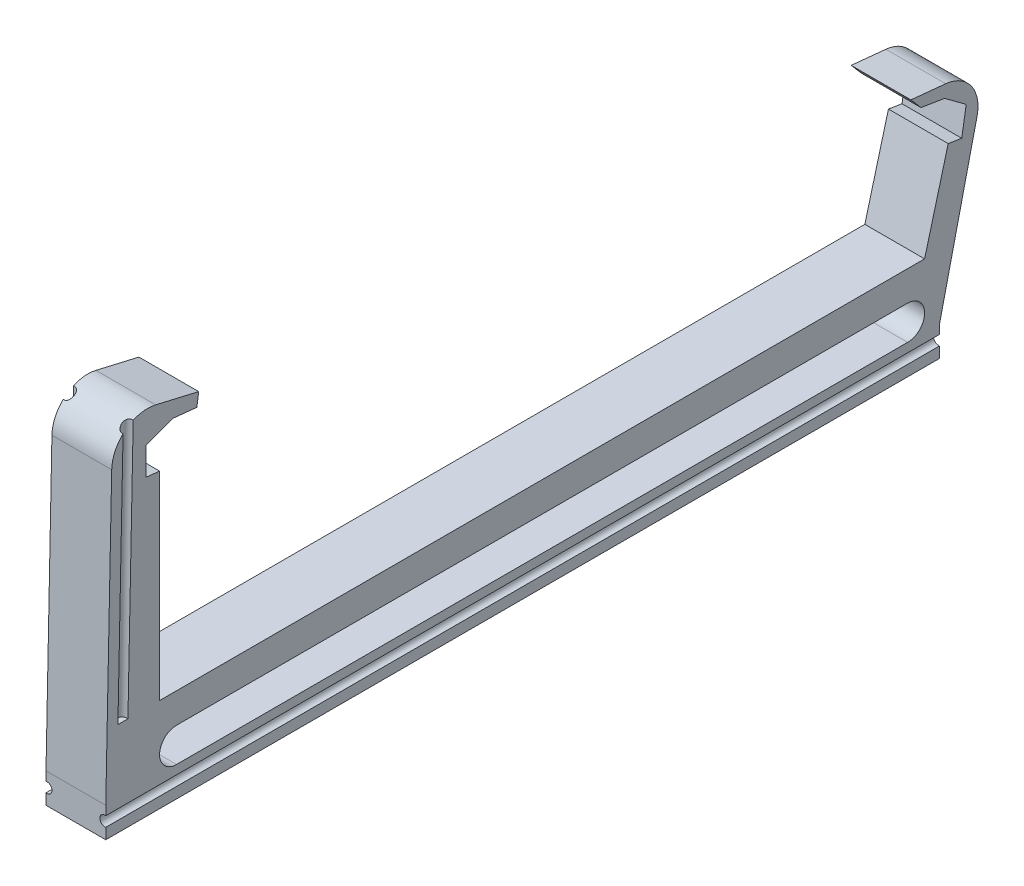
from build123d import *

# Parameters (mm, degrees)
BOSS_EXTRUDE1_DEPTH = 10
CUT_EXTRUDE4_REACH  = 150.602
CUT_EXTRUDE5_DEPTH  = 144.972857609


with BuildPart() as part:
    # Sketch1 → Boss-Extrude1 (new body)
    with BuildSketch(Plane(origin=(0, 0, 0), x_dir=(0, 0, -1), z_dir=(1, 0, 0))):
        with BuildLine():
            Line((0, 0), (128, 0))
            Line((128, 0), (131.946990438, 14.730368851))
            Line((131.946990438, 14.730368851), (134.217403847, 14.362642119))
            Line((134.217403847, 14.362642119), (134.952857311, 18.903468939))
            Line((134.952857311, 18.903468939), (131.341565092, 21.580990302))
            Line((131.341565092, 21.580990302), (127.393020031, 22.220515053))
            Line((127.393020031, 22.220515053), (125.710603817, 24.179837998))
            Line((125.710603817, 24.179837998), (131.520951621, 23.60910455))
            ThreePointArc((131.520951621, 23.60910455), (135.810577018, 21.133985308), (136.778030397, 16.276914661))
            Line((136.778030397, 16.276914661), (130.5, -10.68))
            Line((130.5, -10.68), (130.5, -15.68))
            Line((130.5, -15.68), (-9, -15.68))
            Line((-9, -15.68), (-9, -10.68))
            Line((-9, -10.68), (-8.008635101, 37.449655704))
            ThreePointArc((-8.008635101, 37.449655704), (-5.691899097, 42.063492927), (-0.648979735, 43.169713494))
            Line((-0.648979735, 43.169713494), (6.548278337, 41.493534839))
            Line((6.548278337, 41.493534839), (6.242876448, 39.365871735))
            Line((6.242876448, 39.365871735), (2.263353613, 39.770096924))
            Line((2.263353613, 39.770096924), (-2.28822563, 38.082429484))
            Line((-2.28822563, 38.082429484), (-2.28822563, 33.482429484))
            Line((-2.28822563, 33.482429484), (0, 33.25))
            Line((0, 33.25), (0, 0))
        make_face()
        with BuildLine():
            Line((2.84, -5), (125.16, -5))
            ThreePointArc((125.16, -5), (128, -7.84), (125.16, -10.68))
            Line((125.16, -10.68), (2.84, -10.68))
            ThreePointArc((2.84, -10.68), (0, -7.84), (2.84, -5))
        make_face(mode=Mode.SUBTRACT)
    extrude(amount=BOSS_EXTRUDE1_DEPTH)

    # Cut-Extrude4: up to this plane
    cut_extrude4_end = Plane(origin=(0, 0, 0), z_dir=(0, 1, 0))
    # Sketch2 → Cut-Extrude4 (cut, up to the surface)
    with BuildSketch(Plane(origin=(0, 43.267611016, -0.891217487), x_dir=(1, 0, 0), z_dir=(0, 0.9997879328481811, -0.020593429320073266)), mode=Mode.PRIVATE) as cut_extrude4_sk1:
        with BuildLine():
            Line((0, -5.291493544), (0, -6.964813597))
            ThreePointArc((0, -6.964813597), (1, -6.12815357), (0, -5.291493544))
        make_face()
    cut_extrude4_tool1 = split(extrude(cut_extrude4_sk1.sketch, amount=-CUT_EXTRUDE4_REACH, mode=Mode.PRIVATE), bisect_by=cut_extrude4_end, keep=Keep.BOTH, mode=Mode.PRIVATE)
    cut_extrude4 = cut_extrude4_tool1.solids().sort_by_distance((0.431182, 43.393811, 5.235637))[0]
    add(cut_extrude4, mode=Mode.SUBTRACT)

    # Mirror1: Cut-Extrude4 across plane
    add(cut_extrude4.mirror(Plane(origin=(5, 0, 0), x_dir=(0, 0, 1), z_dir=(1, 0, 0))), mode=Mode.SUBTRACT)

    # Sketch3 → Cut-Extrude5 (cut, symmetric)
    with BuildSketch(Plane.XY):
        with BuildLine():
            ThreePointArc((0, -13.866660027), (1, -13.03), (0, -12.193339973))
            Line((0, -12.193339973), (0, -13.866660027))
        make_face()
    cut_extrude5 = extrude(amount=CUT_EXTRUDE5_DEPTH, both=True, mode=Mode.SUBTRACT)

    # Mirror2: Cut-Extrude5 across plane
    add(cut_extrude5.mirror(Plane(origin=(5, 0, 0), x_dir=(0, 0, 1), z_dir=(1, 0, 0))), mode=Mode.SUBTRACT)


solid = part.part
